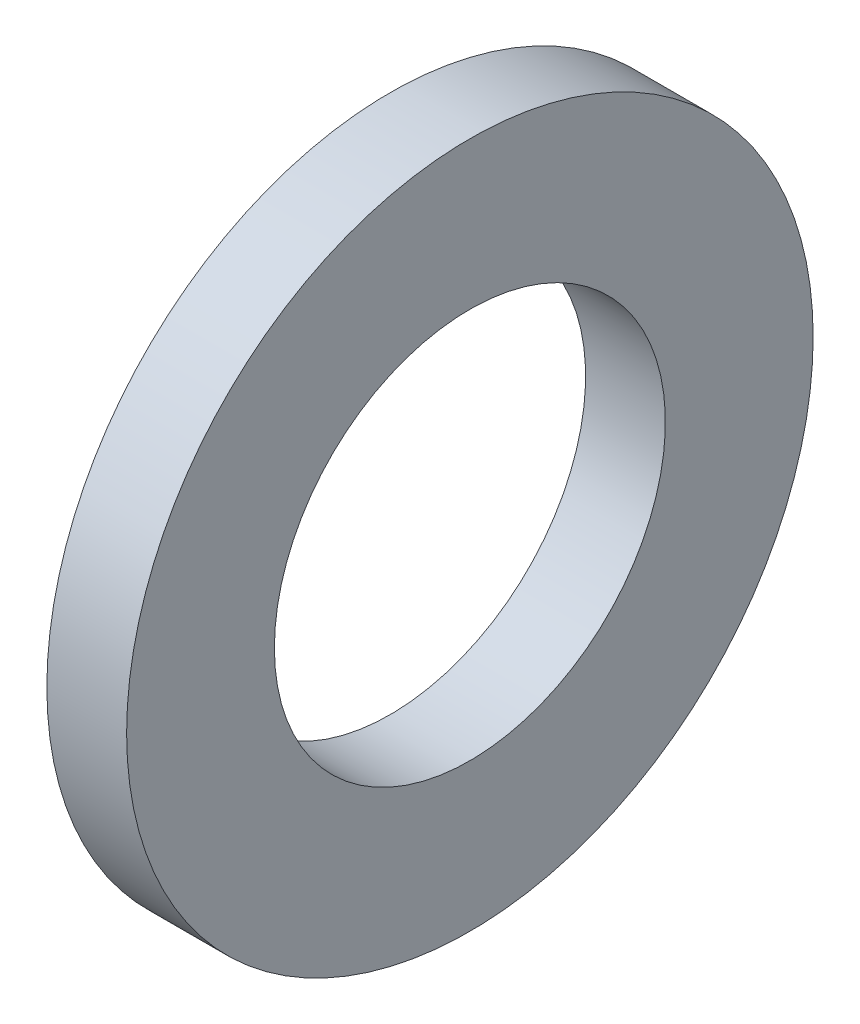
from build123d import *

# Parameters (mm, degrees)
SKETCH3_W = 3.2385
SKETCH3_H = 5.99899994


with BuildPart() as part:
    # Sketch3 → Revolve1 (revolve)
    with BuildSketch(Plane.XY):
        with Locations((3.390149684, 10.93699997)):
            Rectangle(SKETCH3_W, SKETCH3_H)
    revolve(axis=Axis((0, 0, 0), (1, 0, 0)))


solid = part.part
